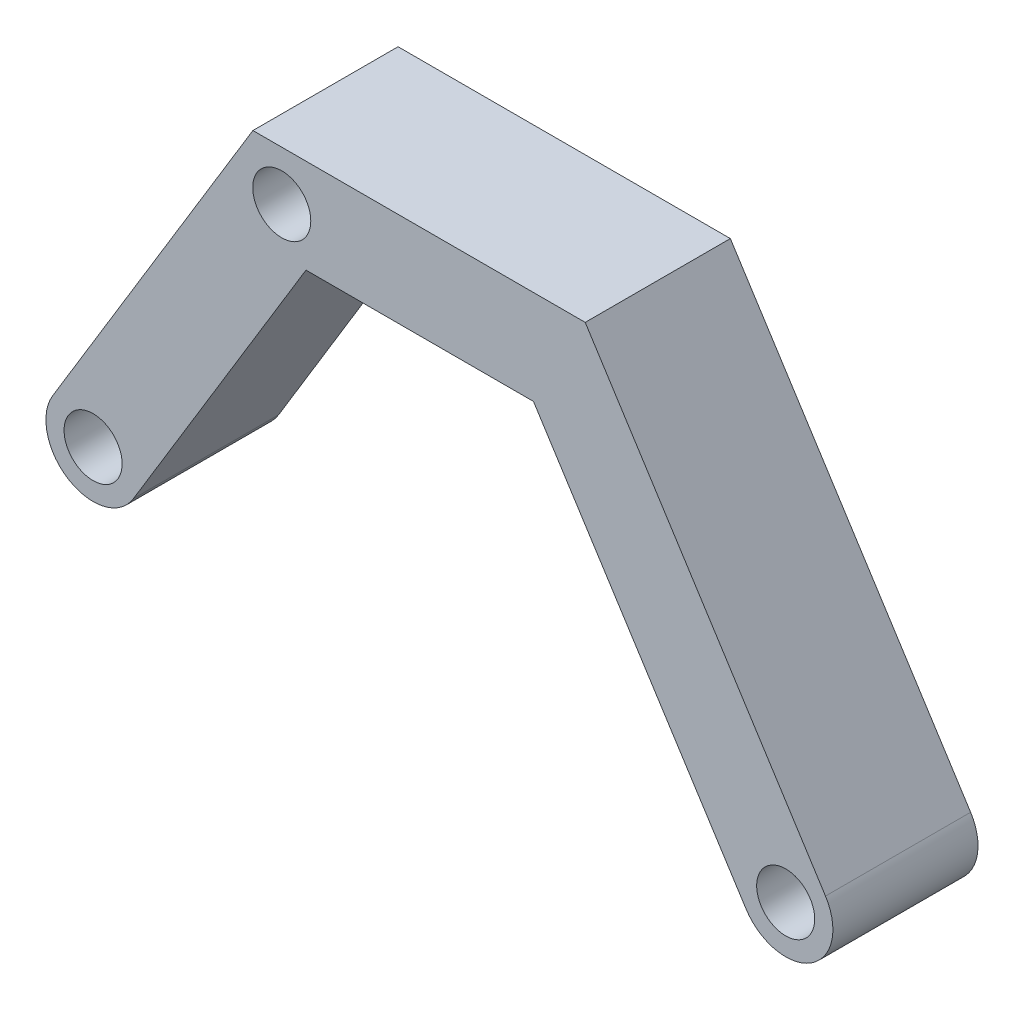
from build123d import *

# Parameters (mm, degrees)
SZKIC1_R                    = 8
DODANIE_WYCI_GNI_CIE1_DEPTH = 40
SZKIC2_R                    = 8
WYTNIJ_WYCI_GNI_CIE2_DEPTH  = 200


with BuildPart() as part:
    # Szkic1 → Dodanie-wyciągnięcie1 (new body)
    with BuildSketch(Plane.XY):
        with BuildLine():
            Line((3.339539238, -8.616464397), (58.496757029, 82.217181769))
            Line((58.496757029, 82.217181769), (150.074280719, 82.217181769))
            Line((150.074280719, 82.217181769), (216.294351194, -21.596573875))
            ThreePointArc((216.294351194, -21.596573875), (212.325412695, -39.547828071), (194.3741585, -35.578889572))
            Line((194.3741585, -35.578889572), (135.819853477, 56.217181769))
            Line((135.819853477, 56.217181769), (73.126827199, 56.217181769))
            Line((73.126827199, 56.217181769), (25.563122599, -22.111365012))
            ThreePointArc((25.563122599, -22.111365012), (7.703880611, -26.475706385), (3.339539238, -8.616464397))
        make_face()
        with Locations((14.451330919, -15.363914704)):
            Circle(SZKIC1_R, mode=Mode.SUBTRACT)
        with Locations((205.334254847, -28.587731723)):
            Circle(SZKIC1_R, mode=Mode.SUBTRACT)
    extrude(amount=DODANIE_WYCI_GNI_CIE1_DEPTH)

    # Szkic2 → Wytnij-wyciągnięcie2 (cut)
    with BuildSketch(Plane.XY.offset(40)):
        with Locations((66.446533252, 68.583395935)):
            Circle(SZKIC2_R)
    extrude(amount=-WYTNIJ_WYCI_GNI_CIE2_DEPTH, mode=Mode.SUBTRACT)


solid = part.part
